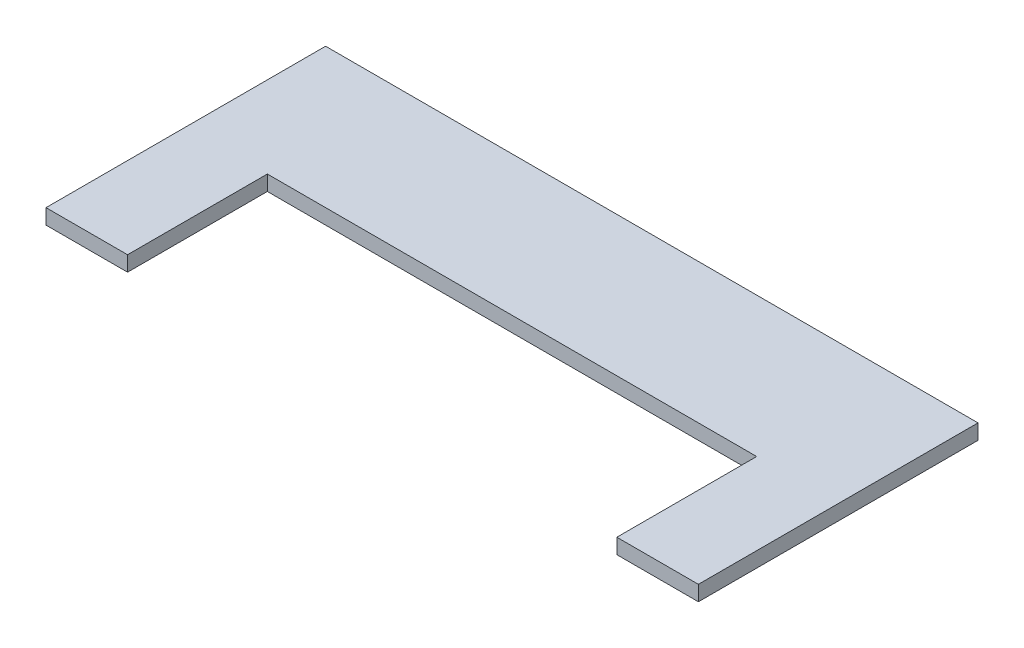
from build123d import *

# Parameters (mm, degrees)
BOSS_EXTRUDE1_DEPTH = 6.5


with BuildPart() as part:
    # Sketch1 → Boss-Extrude1 (new body)
    with BuildSketch(Plane(origin=(0, 0, 0), x_dir=(1, 0, 0), z_dir=(0, 1, 0))):
        Polygon((0, 0), (0, 120), (280, 120), (280, 0), (245, 0), (245, 60), (35, 60), (35, 0), align=None)
    extrude(amount=BOSS_EXTRUDE1_DEPTH)


solid = part.part
